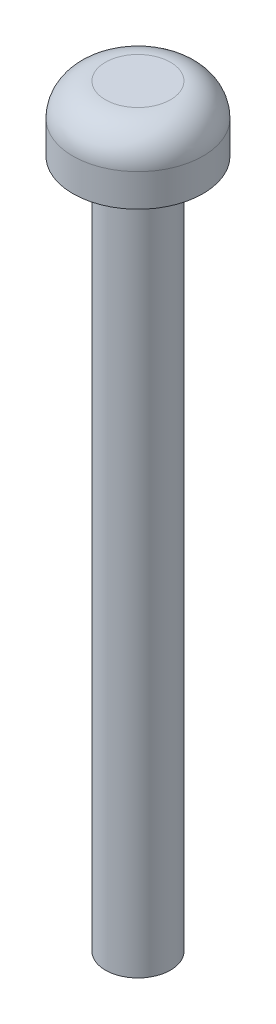
from build123d import *

# Parameters (mm, degrees)
SKETCH1_R           = 3
BOSS_EXTRUDE1_DEPTH = 3
FILLET1_R           = 1.5
SKETCH2_R           = 1.5
BOSS_EXTRUDE2_DEPTH = 31.75


with BuildPart() as part:
    # Sketch1 → Boss-Extrude1 (new body)
    with BuildSketch(Plane(origin=(0, 0, 0), x_dir=(1, 0, 0), z_dir=(0, 1, 0))):
        Circle(SKETCH1_R)
    extrude(amount=BOSS_EXTRUDE1_DEPTH)

    # Fillet1
    fillet1_edges = [part.edges().sort_by_distance(p)[0] for p in [
        (-3, 3, 0),
    ]]
    fillet(fillet1_edges, radius=FILLET1_R)

    # Sketch2 → Boss-Extrude2 (add)
    with BuildSketch(Plane.XZ):
        Circle(SKETCH2_R)
    extrude(amount=BOSS_EXTRUDE2_DEPTH)


solid = part.part
